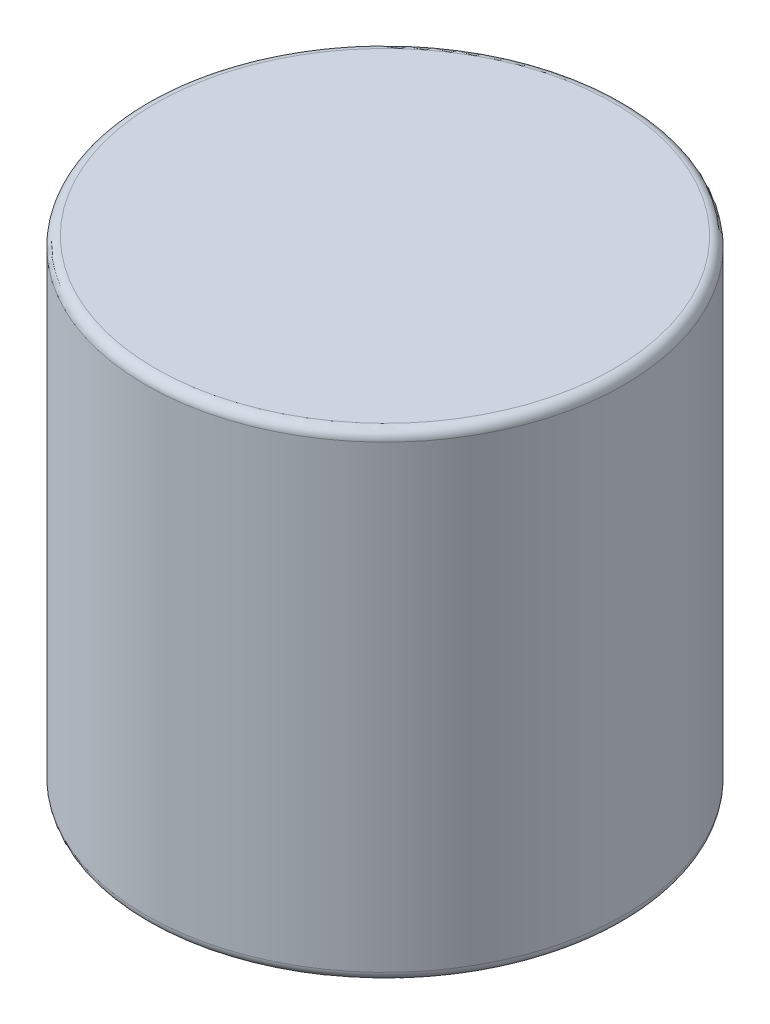
from build123d import *

# Parameters (mm, degrees)
SKETCH1_R           = 5
BOSS_EXTRUDE1_DEPTH = 10
FILLET1_R           = 0.2


with BuildPart() as part:
    # Sketch1 → Boss-Extrude1 (new body)
    with BuildSketch(Plane(origin=(0, 0, 0), x_dir=(1, 0, 0), z_dir=(0, 1, 0))):
        Circle(SKETCH1_R)
    extrude(amount=BOSS_EXTRUDE1_DEPTH)

    # Fillet1
    fillet1_edges = [part.edges().sort_by_distance(p)[0] for p in [
        (-5, 0, 0),
        (-5, 10, 0),
    ]]
    fillet(fillet1_edges, radius=FILLET1_R)


solid = part.part
